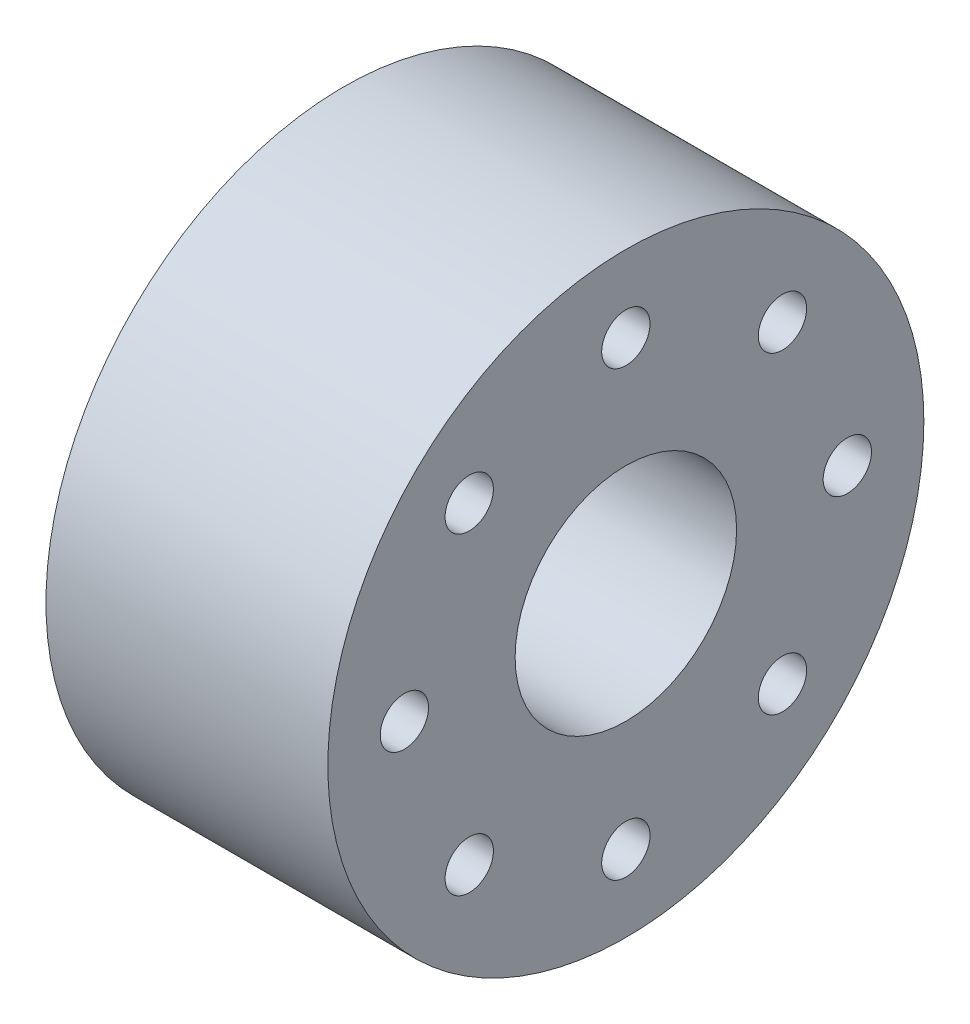
from build123d import *

# Parameters (mm, degrees)
SKETCH1_R               = 14.8
BOSS_EXTRUDE1_DEPTH     = 14
SKETCH2_R               = 1.2
CUT_EXTRUDE1_DEPTH      = 1
CUT_EXTRUDE1_DEPTH_BACK = 15
SKETCH3_R               = 5.5
CUT_EXTRUDE2_DEPTH      = 14
CUT_EXTRUDE3_START      = -9
SKETCH5_R               = 2.5
CUT_EXTRUDE3_DEPTH      = 6


with BuildPart() as part:
    # Sketch1 → Boss-Extrude1 (new body)
    with BuildSketch(Plane(origin=(0, 0, 0), x_dir=(0, 0, -1), z_dir=(1, 0, 0))):
        Circle(SKETCH1_R)
    extrude(amount=BOSS_EXTRUDE1_DEPTH)

    # Sketch2 → Cut-Extrude1 (cut, two sides)
    with BuildSketch(Plane(origin=(14, 0, 0), x_dir=(0, 0, -1), z_dir=(1, 0, 0))) as cut_extrude1_sk:
        with Locations((0, 11)):
            Circle(SKETCH2_R)
        with Locations((7.778174593, 7.778174593)):
            Circle(SKETCH2_R)
        with Locations((11, 0)):
            Circle(SKETCH2_R)
        with Locations((7.778174593, -7.778174593)):
            Circle(SKETCH2_R)
        with Locations((0, -11)):
            Circle(SKETCH2_R)
        with Locations((-7.778174593, -7.778174593)):
            Circle(SKETCH2_R)
        with Locations((-11, 0)):
            Circle(SKETCH2_R)
        with Locations((-7.778174593, 7.778174593)):
            Circle(SKETCH2_R)
    extrude(amount=CUT_EXTRUDE1_DEPTH, mode=Mode.SUBTRACT)
    extrude(cut_extrude1_sk.sketch, amount=-CUT_EXTRUDE1_DEPTH_BACK, mode=Mode.SUBTRACT)

    # Sketch3 → Cut-Extrude2 (cut)
    with BuildSketch(Plane.ZY):
        Circle(SKETCH3_R)
    extrude(amount=-CUT_EXTRUDE2_DEPTH, mode=Mode.SUBTRACT)

    # Sketch5 → Cut-Extrude3 (cut, through all)
    with BuildSketch(Plane(origin=(14, 0, 0), x_dir=(0, 0, -1), z_dir=(1, 0, 0)).offset(CUT_EXTRUDE3_START)):
        with Locations((7.778174593, 7.778174593)):
            Circle(SKETCH5_R)
        with Locations((-7.778174593, -7.778174593)):
            Circle(SKETCH5_R)
        with Locations((7.778174593, -7.778174593)):
            Circle(SKETCH5_R)
        with Locations((-7.778174593, 7.778174593)):
            Circle(SKETCH5_R)
    extrude(amount=-CUT_EXTRUDE3_DEPTH, mode=Mode.SUBTRACT)


solid = part.part
